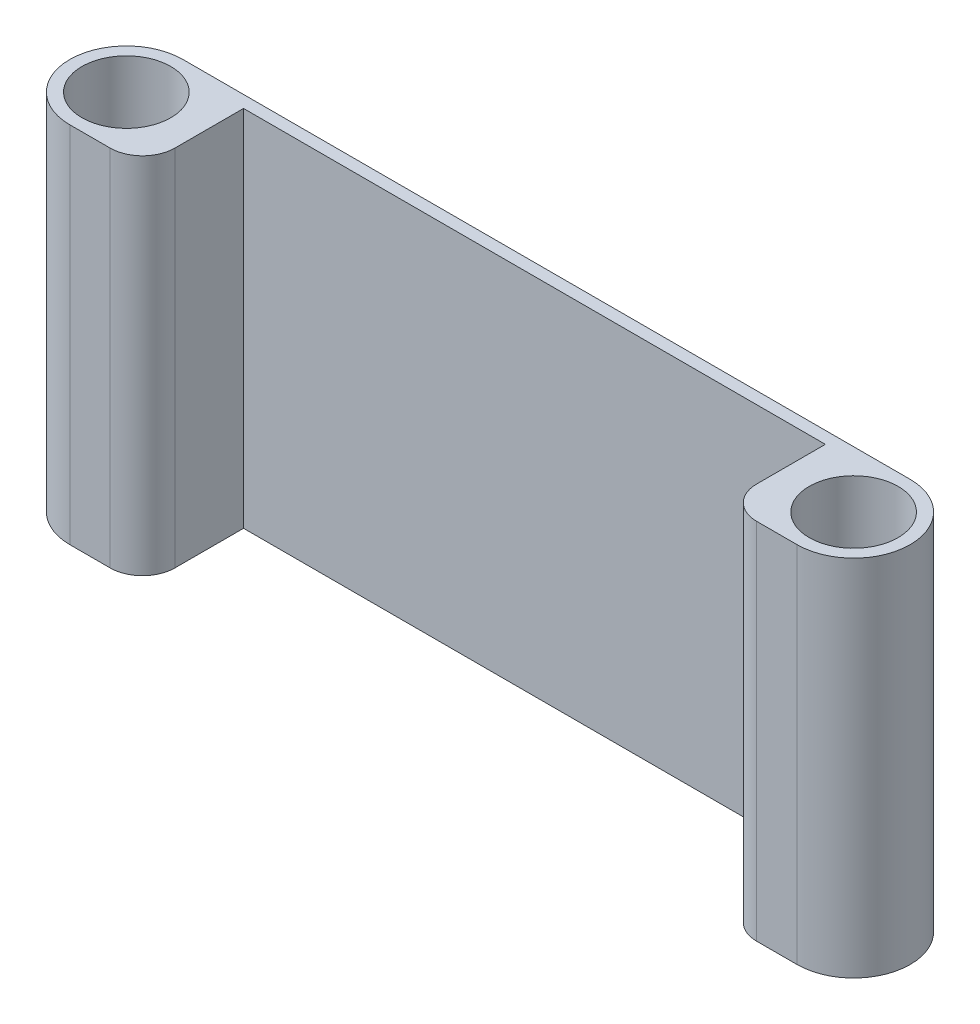
from build123d import *

# Parameters (mm, degrees)
SKETCH1_R           = 11
BOSS_EXTRUDE1_DEPTH = 90
FILLET1_R           = 8


with BuildPart() as part:
    # Sketch1 → Boss-Extrude1 (new body)
    with BuildSketch(Plane(origin=(0, 0, 0), x_dir=(1, 0, 0), z_dir=(0, 1, 0))):
        with BuildLine():
            Line((137.460581558, -14.5), (119.460581558, -14.5))
            Line((119.460581558, -14.5), (119.460581558, 10.5))
            Line((119.460581558, 10.5), (-24.539418442, 10.5))
            Line((-24.539418442, 10.5), (-24.539418442, -14.5))
            Line((-24.539418442, -14.5), (-42.539418442, -14.5))
            ThreePointArc((-42.539418442, -14.5), (-56.539418442, -0.5), (-42.539418442, 13.5))
            Line((-42.539418442, 13.5), (137.460581558, 13.5))
            ThreePointArc((137.460581558, 13.5), (151.460581558, -0.5), (137.460581558, -14.5))
        make_face()
        with Locations((-42.539418442, -0.5)):
            Circle(SKETCH1_R, mode=Mode.SUBTRACT)
        with Locations((137.460581558, -0.5)):
            Circle(SKETCH1_R, mode=Mode.SUBTRACT)
    extrude(amount=BOSS_EXTRUDE1_DEPTH)

    # Fillet1
    fillet1_edges = [part.edges().sort_by_distance(p)[0] for p in [
        (119.460581558, 45, 14.5),
        (-24.539418442, 45, 14.5),
    ]]
    fillet(fillet1_edges, radius=FILLET1_R)


solid = part.part
